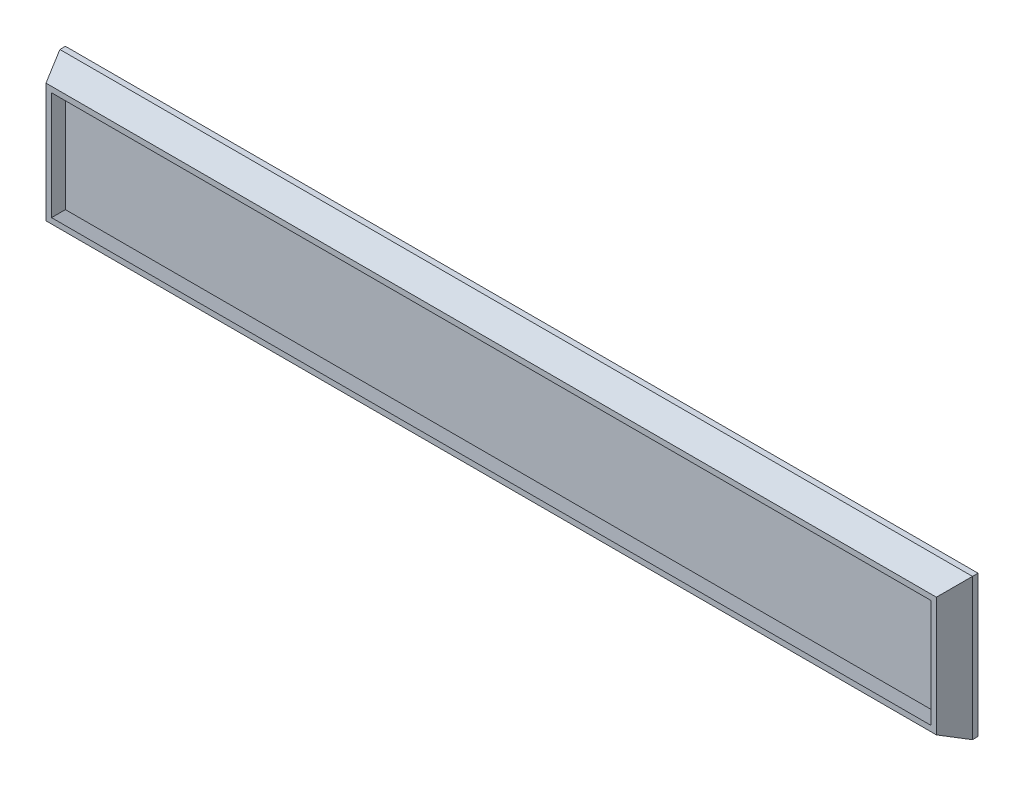
from build123d import *

# Parameters (mm, degrees)
SZKIC1_W                    = 164.5
SZKIC1_H                    = 25.5
DODANIE_WYCI_GNI_CIE1_DEPTH = 1
SZKIC3_W                    = 160.5
SZKIC3_H                    = 21.5
SZKIC2_W                    = 164.5
SZKIC2_H                    = 25.5
SZKIC3_140_W                = 158.5
SZKIC3_140_H                = 19.5
SZKIC2_152_W                = 162.5
SZKIC2_152_H                = 23.5


with BuildPart() as part:
    # Szkic1 → Dodanie-wyciągnięcie1 (new body)
    with BuildSketch(Plane.XY):
        Rectangle(SZKIC1_W, SZKIC1_H)
    extrude(amount=DODANIE_WYCI_GNI_CIE1_DEPTH)

    # Szkic3 → Wyciągnięcie po profilach2 section 0
    with BuildSketch(Plane.XY.offset(5.5)):
        Rectangle(SZKIC3_W, SZKIC3_H)
    # Szkic2 → Wyciągnięcie po profilach2 section 1
    with BuildSketch(Plane.XY.offset(1)):
        Rectangle(SZKIC2_W, SZKIC2_H)
    loft()

    # Szkic3_140 → Wycięcie-wyciągnięcie po profilach1 section 0
    with BuildSketch(Plane.XY.offset(5.5)):
        Rectangle(SZKIC3_140_W, SZKIC3_140_H)
    # Szkic2_152 → Wycięcie-wyciągnięcie po profilach1 section 1
    with BuildSketch(Plane.XY.offset(1)):
        Rectangle(SZKIC2_152_W, SZKIC2_152_H)
    loft(mode=Mode.SUBTRACT)


solid = part.part
